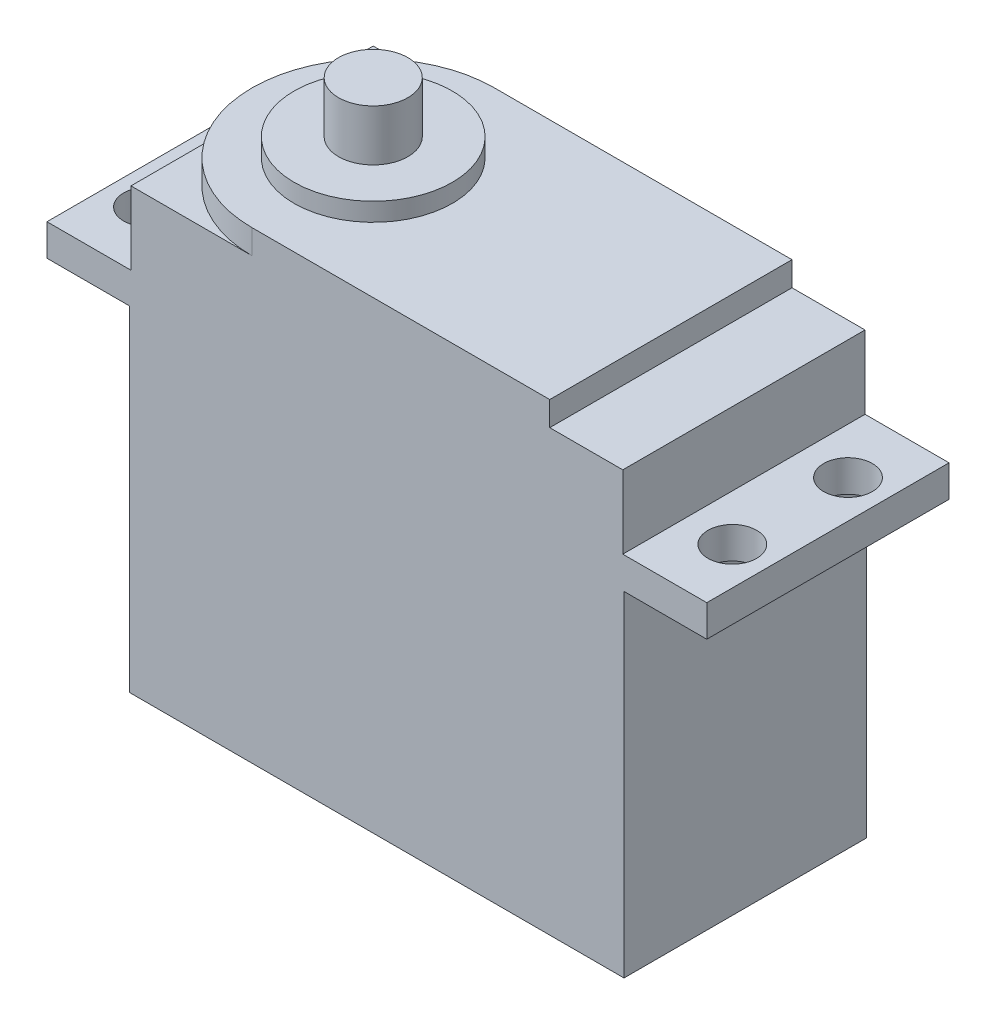
from build123d import *

# Parameters (mm, degrees)
SKETCH1_W           = 40.6
SKETCH1_H           = 19.9
BOSS_EXTRUDE1_DEPTH = 27.5
SKETCH2_W           = 54.2
SKETCH2_H           = 19.9
SKETCH2_R           = 2
BOSS_EXTRUDE2_DEPTH = 2.6
SKETCH3_W           = 40.4
SKETCH3_H           = 19.9
BOSS_EXTRUDE3_DEPTH = 6
SKETCH4_R           = 9.95
BOSS_EXTRUDE4_DEPTH = 2
SKETCH5_R           = 6.5
BOSS_EXTRUDE5_DEPTH = 1.5
SKETCH6_R           = 2.85
BOSS_EXTRUDE6_DEPTH = 4.2


with BuildPart() as part:
    # Sketch1 → Boss-Extrude1 (new body)
    with BuildSketch(Plane(origin=(0, 0, 0), x_dir=(1, 0, 0), z_dir=(0, 1, 0))):
        Rectangle(SKETCH1_W, SKETCH1_H)
    extrude(amount=BOSS_EXTRUDE1_DEPTH)

    # Sketch2 → Boss-Extrude2 (add)
    with BuildSketch(Plane(origin=(0, 27.5, 0), x_dir=(1, 0, 0), z_dir=(0, 1, 0))):
        Rectangle(SKETCH2_W, SKETCH2_H)
        with Locations((-24, 4.75)):
            Circle(SKETCH2_R, mode=Mode.SUBTRACT)
        with Locations((-24, -4.75)):
            Circle(SKETCH2_R, mode=Mode.SUBTRACT)
        with Locations((24, -4.75)):
            Circle(SKETCH2_R, mode=Mode.SUBTRACT)
        with Locations((24, 4.75)):
            Circle(SKETCH2_R, mode=Mode.SUBTRACT)
    extrude(amount=BOSS_EXTRUDE2_DEPTH)

    # Sketch3 → Boss-Extrude3 (add)
    with BuildSketch(Plane(origin=(0, 30.1, 0), x_dir=(1, 0, 0), z_dir=(0, 1, 0))):
        Rectangle(SKETCH3_W, SKETCH3_H)
    extrude(amount=BOSS_EXTRUDE3_DEPTH)

    # Sketch4 → Boss-Extrude4 (add)
    with BuildSketch(Plane(origin=(0, 36.1, 0), x_dir=(1, 0, 0), z_dir=(0, 1, 0))):
        with BuildLine():
            Line((14.2, 9.95), (-10.25, 9.95))
            ThreePointArc((-10.25, 9.95), (-3.214287527, 7.035712473), (-0.3, 0))
            ThreePointArc((-0.3, 0), (-3.214287527, -7.035712473), (-10.25, -9.95))
            Line((-10.25, -9.95), (14.2, -9.95))
            Line((14.2, -9.95), (14.2, 9.95))
        make_face()
        with Locations((-10.25, 0)):
            Circle(SKETCH4_R)
    extrude(amount=BOSS_EXTRUDE4_DEPTH)

    # Sketch5 → Boss-Extrude5 (add)
    with BuildSketch(Plane(origin=(0, 38.1, 0), x_dir=(1, 0, 0), z_dir=(0, 1, 0))):
        with Locations((-10.25, 0)):
            Circle(SKETCH5_R)
    extrude(amount=BOSS_EXTRUDE5_DEPTH)

    # Sketch6 → Boss-Extrude6 (add)
    with BuildSketch(Plane(origin=(0, 39.6, 0), x_dir=(1, 0, 0), z_dir=(0, 1, 0))):
        with Locations((-10.25, 0)):
            Circle(SKETCH6_R)
    extrude(amount=BOSS_EXTRUDE6_DEPTH)


solid = part.part
